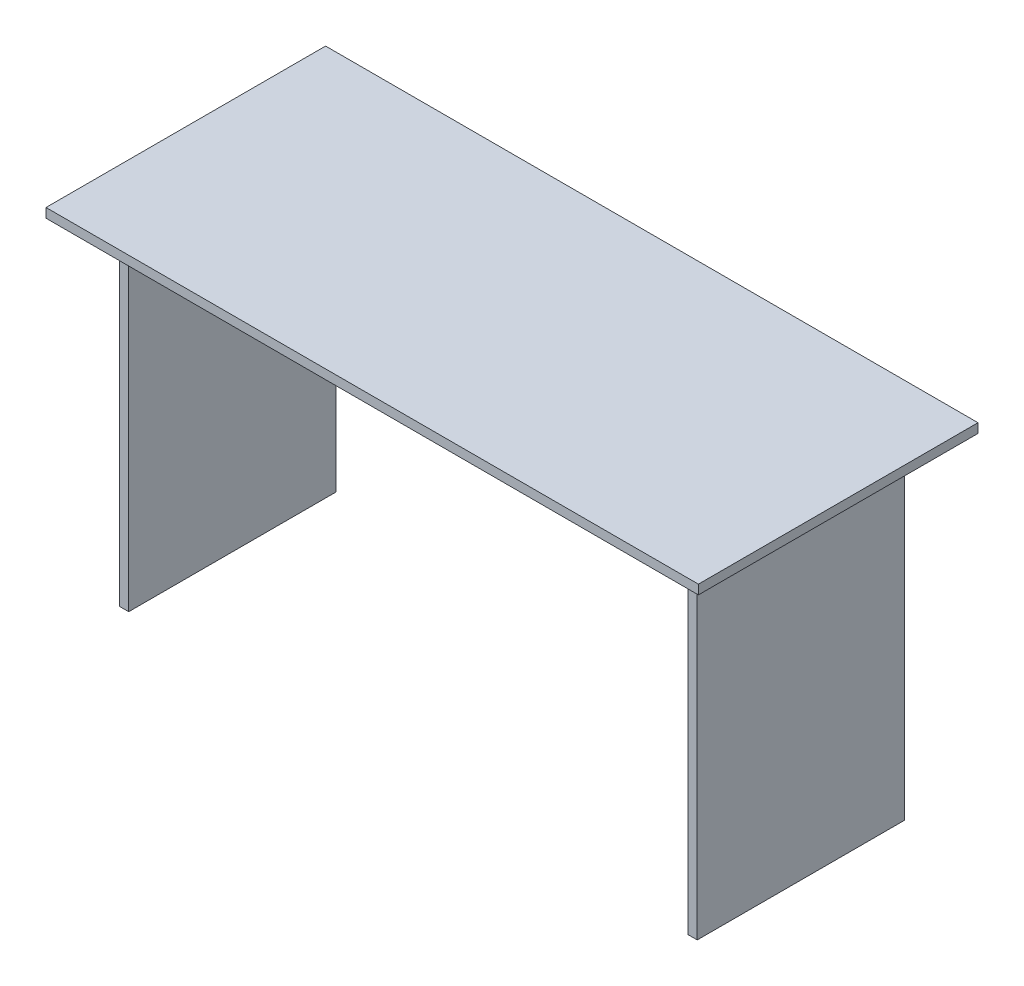
from build123d import *

# Parameters (mm, degrees)
SKETCH1_W           = 1400
SKETCH1_H           = 600
BOSS_EXTRUDE1_DEPTH = 20
SKETCH2_W           = 20
SKETCH2_H           = 445
BOSS_EXTRUDE2_DEPTH = 720
SKETCH3_W           = 1200
SKETCH3_H           = 20
BOSS_EXTRUDE3_DEPTH = 450
SKETCH4_W           = 1200
SKETCH4_H           = 150
BOSS_EXTRUDE4_DEPTH = 20


with BuildPart() as part:
    # Sketch1 → Boss-Extrude1 (new body)
    with BuildSketch(Plane(origin=(0, 0, 0), x_dir=(1, 0, 0), z_dir=(0, 1, 0))):
        Rectangle(SKETCH1_W, SKETCH1_H)
    extrude(amount=-BOSS_EXTRUDE1_DEPTH)

    # Sketch2 → Boss-Extrude2 (add)
    with BuildSketch(Plane.XZ.offset(20)):
        with Locations((610, 0)):
            Rectangle(SKETCH2_W, SKETCH2_H)
        with Locations((-610, 0)):
            Rectangle(SKETCH2_W, SKETCH2_H)
    extrude(amount=BOSS_EXTRUDE2_DEPTH)

    # Sketch3 → Boss-Extrude3 (add)
    with BuildSketch(Plane.XZ.offset(20)):
        with Locations((0, -187.5)):
            Rectangle(SKETCH3_W, SKETCH3_H)
    extrude(amount=BOSS_EXTRUDE3_DEPTH)

    # Sketch4 → Boss-Extrude4 (add)
    with BuildSketch(Plane.XZ.offset(20)):
        with Locations((0, -102.5)):
            Rectangle(SKETCH4_W, SKETCH4_H)
        with Locations((0, 102.5)):
            Rectangle(SKETCH4_W, SKETCH4_H)
    extrude(amount=BOSS_EXTRUDE4_DEPTH)


solid = part.part
